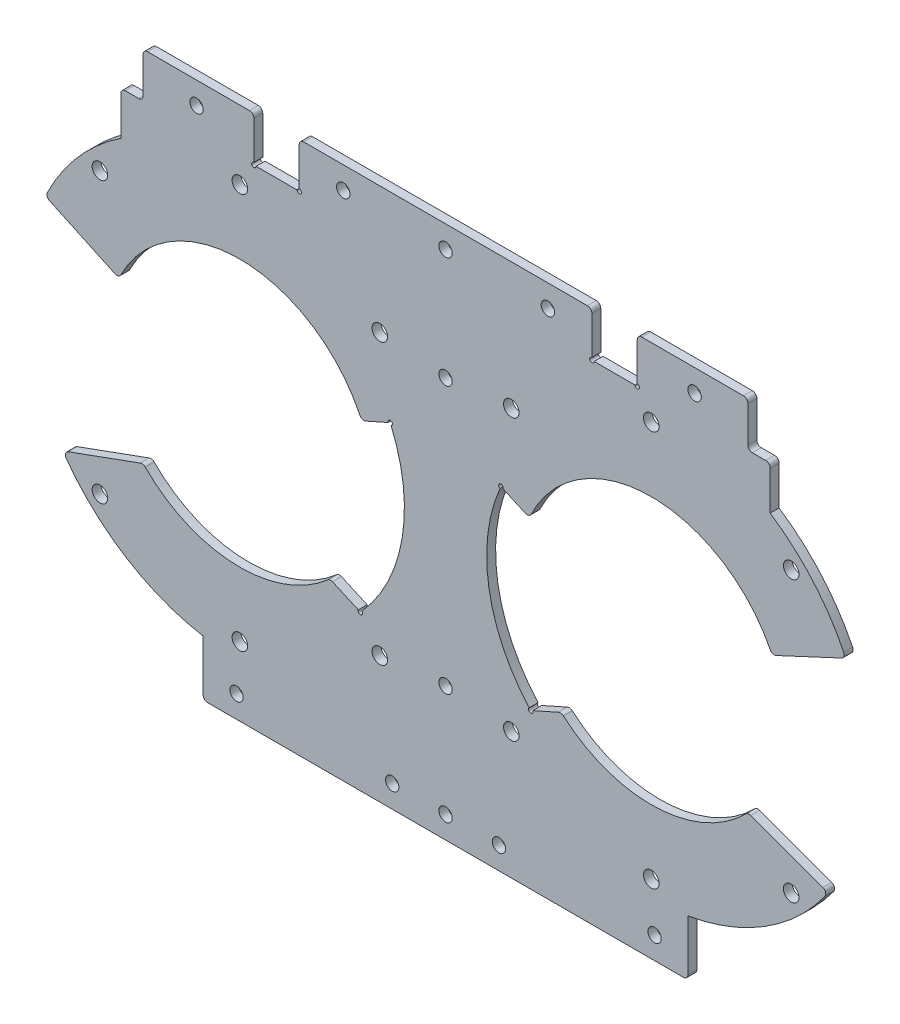
from build123d import *

# Parameters (mm, degrees)
SKETCH_1_R          = 1.5
SKETCH_1_R_2        = 1.75
EXTRUDE_1_DEPTH     = 2
CUT_EXTRUDE_3_DEPTH = 10
SKETCH_2_R          = 0.5
CUT_EXTRUDE_1_DEPTH = 10
SKETCH_8_W          = 5
SKETCH_8_H          = 10.1
CUT_EXTRUDE_4_DEPTH = 10
FILLET_2_R          = 1


with BuildPart() as part:
    # 草图1 → 凸台-拉伸1 (new body)
    with BuildSketch(Plane.XY):
        with BuildLine():
            Line((-54.5, -47.539457296), (-54.5, -60))
            Line((-54.5, -60), (54.5, -60))
            Line((54.5, -60), (54.5, -47.539457296))
            ThreePointArc((54.5, -47.539457296), (72.332250623, -40.592840532), (86.061310432, -27.260265254))
            Line((86.061310432, -27.260265254), (67.983033669, -20.680310625))
            ThreePointArc((67.983033669, -20.680310625), (16.643405824, 4.842476776), (73.439233611, 12.678547852))
            Line((73.439233611, 12.678547852), (89.979350725, 20.391331129))
            ThreePointArc((89.979350725, 20.391331129), (82.849108186, 31.441497738), (73, 40.155946011))
            Line((73, 40.155946011), (73, 60))
            Line((73, 60), (43.1, 60))
            Line((43.1, 60), (43.1, 49.9))
            Line((43.1, 49.9), (32.9, 49.9))
            Line((32.9, 49.9), (32.9, 60))
            Line((32.9, 60), (-32.9, 60))
            Line((-32.9, 60), (-32.9, 49.9))
            Line((-32.9, 49.9), (-43.1, 49.9))
            Line((-43.1, 49.9), (-43.1, 60))
            Line((-43.1, 60), (-73, 60))
            Line((-73, 60), (-73, 40.155946011))
            ThreePointArc((-73, 40.155946011), (-82.849108186, 31.441497738), (-89.979350725, 20.391331129))
            Line((-89.979350725, 20.391331129), (-73.439233611, 12.678547852))
            ThreePointArc((-73.439233611, 12.678547852), (-16.643405824, 4.842476776), (-67.983033669, -20.680310625))
            Line((-67.983033669, -20.680310625), (-86.061310432, -27.260265254))
            ThreePointArc((-86.061310432, -27.260265254), (-72.332250623, -40.592840532), (-54.5, -47.539457296))
        make_face()
        with Locations((-47, -55)):
            Circle(SKETCH_1_R, mode=Mode.SUBTRACT)
        with Locations((-77.716251763, -31.466251763)):
            Circle(SKETCH_1_R_2, mode=Mode.SUBTRACT)
        with Locations((-46.25, -44.5)):
            Circle(SKETCH_1_R_2, mode=Mode.SUBTRACT)
        with Locations((-12, -55)):
            Circle(SKETCH_1_R, mode=Mode.SUBTRACT)
        with Locations((-14.783748237, -31.466251763)):
            Circle(SKETCH_1_R_2, mode=Mode.SUBTRACT)
        with Locations((0, -55)):
            Circle(SKETCH_1_R, mode=Mode.SUBTRACT)
        with Locations((12, -55)):
            Circle(SKETCH_1_R, mode=Mode.SUBTRACT)
        with Locations((0, -30)):
            Circle(SKETCH_1_R, mode=Mode.SUBTRACT)
        with Locations((14.783748237, -31.466251763)):
            Circle(SKETCH_1_R_2, mode=Mode.SUBTRACT)
        with Locations((47, -55)):
            Circle(SKETCH_1_R, mode=Mode.SUBTRACT)
        with Locations((46.25, -44.5)):
            Circle(SKETCH_1_R_2, mode=Mode.SUBTRACT)
        with Locations((77.716251763, -31.466251763)):
            Circle(SKETCH_1_R_2, mode=Mode.SUBTRACT)
        with Locations((-77.716251763, 31.466251763)):
            Circle(SKETCH_1_R_2, mode=Mode.SUBTRACT)
        with Locations((-46.25, 44.5)):
            Circle(SKETCH_1_R_2, mode=Mode.SUBTRACT)
        with Locations((-56, 55)):
            Circle(SKETCH_1_R, mode=Mode.SUBTRACT)
        with Locations((-14.783748237, 31.466251763)):
            Circle(SKETCH_1_R_2, mode=Mode.SUBTRACT)
        with Locations((-23, 55)):
            Circle(SKETCH_1_R, mode=Mode.SUBTRACT)
        with Locations((0, 30)):
            Circle(SKETCH_1_R, mode=Mode.SUBTRACT)
        with Locations((14.783748237, 31.466251763)):
            Circle(SKETCH_1_R_2, mode=Mode.SUBTRACT)
        with Locations((0, 55)):
            Circle(SKETCH_1_R, mode=Mode.SUBTRACT)
        with Locations((23, 55)):
            Circle(SKETCH_1_R, mode=Mode.SUBTRACT)
        with Locations((46.25, 44.5)):
            Circle(SKETCH_1_R_2, mode=Mode.SUBTRACT)
        with Locations((77.716251763, 31.466251763)):
            Circle(SKETCH_1_R_2, mode=Mode.SUBTRACT)
        with Locations((56, 55)):
            Circle(SKETCH_1_R, mode=Mode.SUBTRACT)
    extrude(amount=EXTRUDE_1_DEPTH)

    # 草图7 → 切除-拉伸3 (cut)
    with BuildSketch(Plane.XY.offset(2)):
        with BuildLine():
            Line((19.156748699, -25.198327999), (26.012492454, -22.145954221))
            ThreePointArc((26.012492454, -22.145954221), (16.882810612, -6.129289311), (18.843636271, 12.202099292))
            Line((18.843636271, 12.202099292), (12.448818067, 15.049255794))
            ThreePointArc((12.448818067, 15.049255794), (9.753424818, -6.08276253), (19.156748699, -25.198327999))
        make_face()
    cut_extrude_3 = extrude(amount=-CUT_EXTRUDE_3_DEPTH, mode=Mode.SUBTRACT)

    # 镜向2: 切除-拉伸3 across plane
    add(cut_extrude_3.mirror(Plane(origin=(0, 0, 0), x_dir=(0, 0, 1), z_dir=(1, 0, 0))), mode=Mode.SUBTRACT)

    # 草图2 → 切除-拉伸1 (cut)
    with BuildSketch(Plane.XY.offset(2)):
        with Locations((-43.1, 49.9)):
            Circle(SKETCH_2_R)
        with Locations((-32.9, 49.9)):
            Circle(SKETCH_2_R)
        with Locations((32.9, 49.9)):
            Circle(SKETCH_2_R)
        with Locations((43.1, 49.9)):
            Circle(SKETCH_2_R)
        with Locations((-12.448818067, 15.049255794)):
            Circle(SKETCH_2_R)
        with Locations((12.448818067, 15.049255794)):
            Circle(SKETCH_2_R)
        with Locations((-19.156748699, -25.198327999)):
            Circle(SKETCH_2_R)
        with Locations((19.156748699, -25.198327999)):
            Circle(SKETCH_2_R)
    extrude(amount=-CUT_EXTRUDE_1_DEPTH, mode=Mode.SUBTRACT)

    # 草图8 → 切除-拉伸4 (cut)
    with BuildSketch(Plane(origin=(0, 0, 0), x_dir=(-1, 0, 0), z_dir=(0, 0, -1))):
        with Locations((70.5, 54.95)):
            Rectangle(SKETCH_8_W, SKETCH_8_H)
        with Locations((-70.5, 54.95)):
            Rectangle(SKETCH_8_W, SKETCH_8_H)
    extrude(amount=-CUT_EXTRUDE_4_DEPTH, mode=Mode.SUBTRACT)

    # 圆角2
    fillet_2_edges = [part.edges().sort_by_distance(p)[0] for p in [
        (18.843636271, 12.202099292, 1),
        (26.012492454, -22.145954221, 1),
        (-26.012492454, -22.145954221, 1),
        (-18.843636271, 12.202099292, 1),
        (-73, 49.9, 1),
        (68, 60, 1),
        (-68, 49.9, 1),
        (-68, 60, 1),
        (68, 49.9, 1),
        (73, 49.9, 1),
        (-67.983033669, -20.680310625, 1),
        (-73.439233611, 12.678547852, 1),
        (-89.979350725, 20.391331129, 1),
        (-43.1, 60, 1),
        (-32.9, 60, 1),
        (32.9, 60, 1),
        (43.1, 60, 1),
        (89.979350725, 20.391331129, 1),
        (73.439233611, 12.678547852, 1),
        (67.983033669, -20.680310625, 1),
        (86.061310432, -27.260265254, 1),
        (54.5, -60, 1),
        (-54.5, -60, 1),
        (-86.061310432, -27.260265254, 1),
    ]]
    fillet(fillet_2_edges, radius=FILLET_2_R)


solid = part.part
